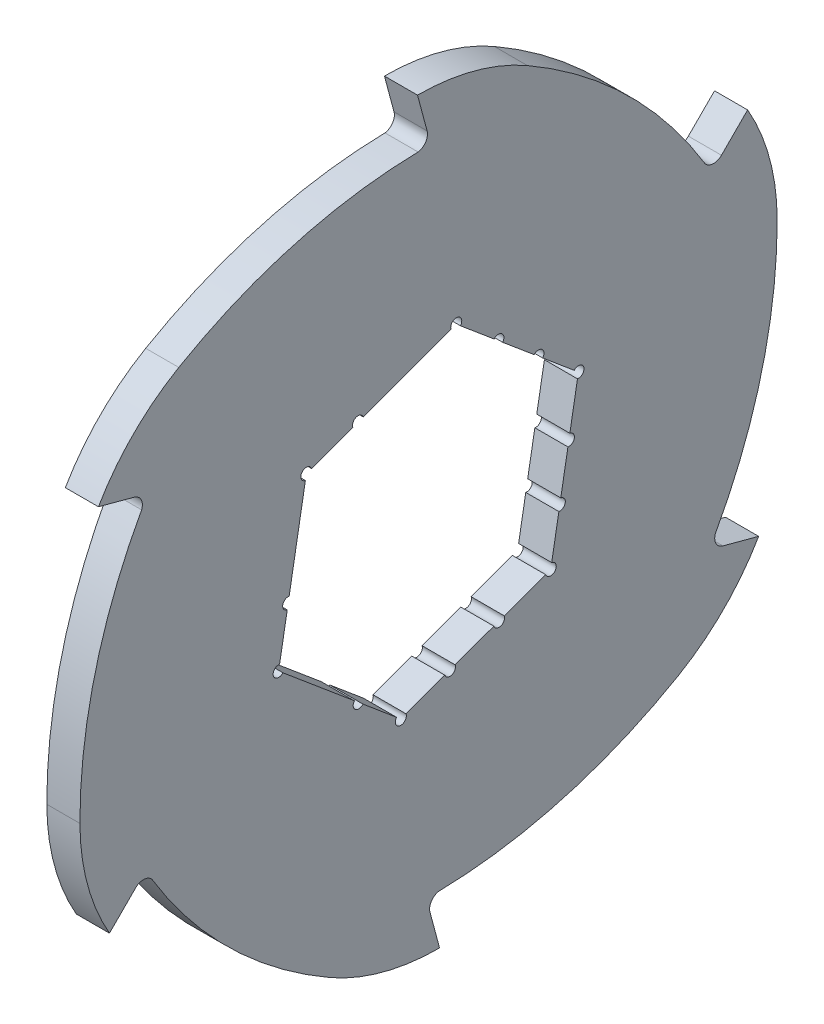
from build123d import *

# Parameters (mm, degrees)
SKETCH1_R                = 59
EXTRUDE1_DEPTH           = 3
EXTRUDE2_DEPTH           = 3
CIRPATTERN1_COUNT        = 6
F_2_0_2_DIAMETER_HOLE1_D = 2
F_2_0_2_DIAMETER_HOLE3_D = 2
F_2_0_2_DIAMETER_HOLE4_D = 2
CIRPATTERN2_COUNT        = 6
CIRPATTERN3_COUNT        = 3
CIRPATTERN3_ANGLE        = 120


with BuildPart() as part:
    # Sketch1 → Extrude1 (new, symmetric)
    with BuildSketch(Plane(origin=(0, 0, 0), x_dir=(0, 0, -1), z_dir=(1, 0, 0))):
        Circle(SKETCH1_R)
        Polygon((27.180842557, 9.893017633), (5.022816688, 28.485808967), (-22.158025869, 18.592791334), (-27.180842557, -9.893017633), (-5.022816688, -28.485808967), (22.158025869, -18.592791334), align=None, mode=Mode.SUBTRACT)
    extrude(amount=EXTRUDE1_DEPTH, both=True)

    # Sketch2 → Extrude2 (add, symmetric)
    with BuildSketch(Plane(origin=(0, 0, 0), x_dir=(0, 0, -1), z_dir=(1, 0, 0))):
        with BuildLine():
            Line((-2, 67.961805723), (-0.262709442, 61.478149092))
            ThreePointArc((-0.262709442, 61.478149092), (-0.58620663, 59.77173183), (-2.122608272, 58.961805723))
            ThreePointArc((-2.122608272, 58.961805723), (28.679663449, 51.560419941), (51.21368579, 29.294340542))
            ThreePointArc((51.21368579, 29.294340542), (36.791707484, 48.186627241), (17.927108603, 62.644803614))
            ThreePointArc((17.927108603, 62.644803614), (8.312130826, 66.609702921), (-2, 67.961805723))
        make_face()
    extrude2 = extrude(amount=EXTRUDE2_DEPTH, both=True)

    # CirPattern1: Extrude2 ×6 about axis
    cirpattern1_axis = Axis((0, 0, 0), (1, 0, 0))
    for i in range(1, CIRPATTERN1_COUNT):
        add(extrude2.rotate(cirpattern1_axis, i * 360 / CIRPATTERN1_COUNT))

    # Ø2.0 (2) Diameter Hole1 (through all)
    with Locations(Plane(origin=(3, 0, 0), x_dir=(0, 0, -1), z_dir=(1, 0, 0))):
        with Locations((5.022816688, 28.485808967), (27.180842557, 9.893017633), (22.158025869, -18.592791334), (-5.022816688, -28.485808967), (-27.180842557, -9.893017633), (-22.158025869, 18.592791334)):
            Hole(F_2_0_2_DIAMETER_HOLE1_D / 2)

    # Ø2.0 (2) Diameter Hole3 (through all)
    with Locations(Plane(origin=(3, 0, 0), x_dir=(0, 0, -1), z_dir=(1, 0, 0))):
        with Locations((12.664173459, 22.073949319)):
            f_2_0_2_diameter_hole3 = Hole(F_2_0_2_DIAMETER_HOLE3_D / 2)

    # Ø2.0 (2) Diameter Hole4 (through all)
    with Locations(Plane(origin=(3, 0, 0), x_dir=(0, 0, -1), z_dir=(1, 0, 0))):
        with Locations((19.922508008, 15.983483476)):
            f_2_0_2_diameter_hole4 = Hole(F_2_0_2_DIAMETER_HOLE4_D / 2)

    # CirPattern2: Ø2.0 (2) Diameter Hole3 ×6 about axis
    cirpattern2_axis = Axis((0, 0, 0), (1, 0, 0))
    for i in range(1, CIRPATTERN2_COUNT):
        add(f_2_0_2_diameter_hole3.rotate(cirpattern2_axis, i * 360 / CIRPATTERN2_COUNT), mode=Mode.SUBTRACT)

    # CirPattern3: Ø2.0 (2) Diameter Hole4 ×3 about axis
    cirpattern3_axis = Axis((0, 0, 0), (-1, 0, 0))
    for i in range(1, CIRPATTERN3_COUNT):
        add(f_2_0_2_diameter_hole4.rotate(cirpattern3_axis, i * CIRPATTERN3_ANGLE / (CIRPATTERN3_COUNT - 1)), mode=Mode.SUBTRACT)


solid = part.part
